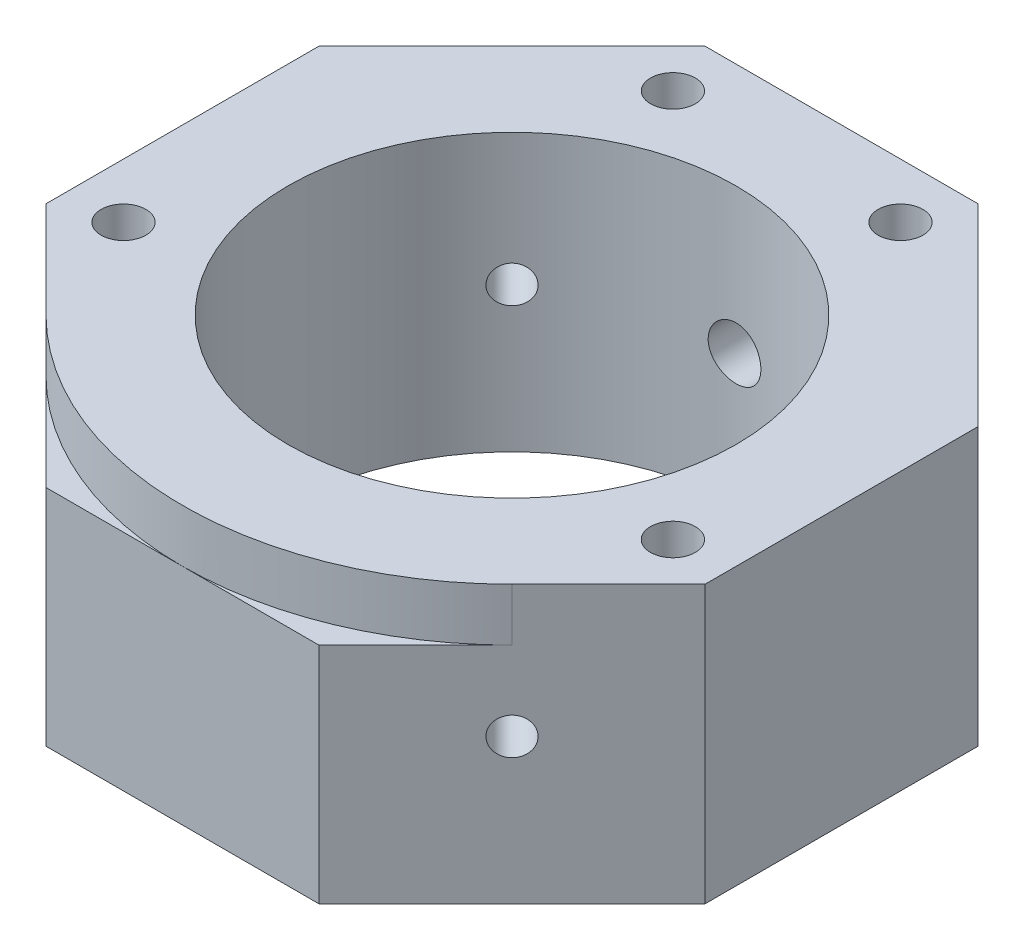
from build123d import *

# Parameters (mm, degrees)
SKETCH1_R                                           = 17
BOSS_EXTRUDE1_DEPTH                                 = 21
CBORE_FOR_M3_HEX_SOCKET_HEAD_CAP_SCREW1_D           = 3.4
CBORE_FOR_M3_HEX_SOCKET_HEAD_CAP_SCREW1_DEPTH       = 21
CBORE_FOR_M3_HEX_SOCKET_HEAD_CAP_SCREW1_CBORE_D     = 6.5
CBORE_FOR_M3_HEX_SOCKET_HEAD_CAP_SCREW1_CBORE_DEPTH = 3.4
M3X0_2_TAPPED_HOLE1_D                               = 2.8
M3X0_2_TAPPED_HOLE2_D                               = 2.8
CUT_EXTRUDE3_REACH                                  = 52
SKETCH12_R                                          = 2
CUT_EXTRUDE4_DEPTH                                  = 4


with BuildPart() as part:
    # Sketch1 → Boss-Extrude1 (new body)
    with BuildSketch(Plane(origin=(0, 0, 0), x_dir=(1, 0, 0), z_dir=(0, 1, 0))):
        Polygon((25, -10.355339059), (25, 10.355339059), (10.355339059, 25), (-10.355339059, 25), (-25, 10.355339059), (-25, -10.355339059), (-10.355339059, -25), (10.355339059, -25), align=None)
        Circle(SKETCH1_R, mode=Mode.SUBTRACT)
    extrude(amount=BOSS_EXTRUDE1_DEPTH)

    # CBORE for M3 Hex Socket Head Cap Screw1
    with Locations(Plane(origin=(0, 0, 0), x_dir=(-1, 0, 0), z_dir=(0, -1, 0))):
        with Locations((20.842542104, -8.633263614), (-20.842542104, -8.633263614), (8.633263614, 20.842542104), (-8.633263614, 20.842542104)):
            CounterBoreHole(CBORE_FOR_M3_HEX_SOCKET_HEAD_CAP_SCREW1_D / 2, CBORE_FOR_M3_HEX_SOCKET_HEAD_CAP_SCREW1_CBORE_D / 2, CBORE_FOR_M3_HEX_SOCKET_HEAD_CAP_SCREW1_CBORE_DEPTH, depth=CBORE_FOR_M3_HEX_SOCKET_HEAD_CAP_SCREW1_DEPTH)

    # M3x0.2 Tapped Hole1 (through all)
    with Locations(Plane(origin=(17.67766953, 0, 17.67766953), x_dir=(0.707106781, 0, -0.707106781), z_dir=(0.707106781, 0, 0.707106781))):
        with Locations((0, 11)):
            Hole(M3X0_2_TAPPED_HOLE1_D / 2)

    # M3x0.2 Tapped Hole2 (through all)
    with Locations(Plane(origin=(-17.67766953, 0, 17.67766953), x_dir=(0.707106781, 0, 0.707106781), z_dir=(-0.707106781, 0, 0.707106781))):
        with Locations((0, 13.5)):
            Hole(M3X0_2_TAPPED_HOLE2_D / 2)

    # Sketch12 → Cut-Extrude3 (cut, up to next)
    with BuildSketch(Plane(origin=(0, 0, -25), x_dir=(-1, 0, 0), z_dir=(0, 0, -1)), mode=Mode.PRIVATE) as cut_extrude3_sk1:
        with Locations((0, 10)):
            Circle(SKETCH12_R)
    cut_extrude3_tool1 = extrude(cut_extrude3_sk1.sketch, amount=-CUT_EXTRUDE3_REACH, mode=Mode.PRIVATE) & part.part
    add(cut_extrude3_tool1.solids().sort_by_distance((0, 10, -25))[0], mode=Mode.SUBTRACT)

    # Sketch13 → Cut-Extrude4 (cut)
    with BuildSketch(Plane(origin=(0, 21, 0), x_dir=(1, 0, 0), z_dir=(0, 1, 0))):
        with BuildLine():
            Line((17.67766953, -17.67766953), (17.67766953, -26.659644855))
            Line((17.67766953, -26.659644855), (-17.67766953, -26.659644855))
            Line((-17.67766953, -26.659644855), (-17.67766953, -17.67766953))
            ThreePointArc((-17.67766953, -17.67766953), (0, -25), (17.67766953, -17.67766953))
        make_face()
    extrude(amount=-CUT_EXTRUDE4_DEPTH, mode=Mode.SUBTRACT)


solid = part.part
